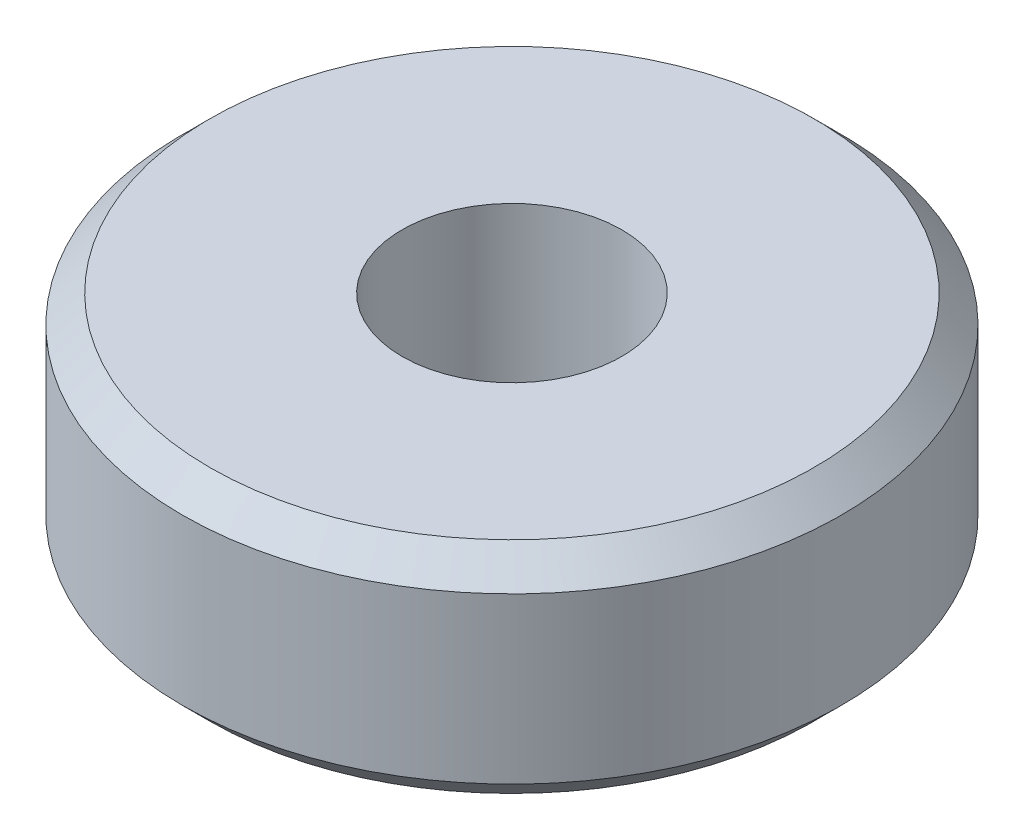
from build123d import *

# Parameters (mm, degrees)
SKETCH1_R           = 6
SKETCH1_R_2         = 2
BOSS_EXTRUDE1_DEPTH = 4
CHAMFER1_SIZE       = 0.5


with BuildPart() as part:
    # Sketch1 → Boss-Extrude1 (new body)
    with BuildSketch(Plane(origin=(0, 0, 0), x_dir=(1, 0, 0), z_dir=(0, 1, 0))):
        Circle(SKETCH1_R)
        Circle(SKETCH1_R_2, mode=Mode.SUBTRACT)
    extrude(amount=BOSS_EXTRUDE1_DEPTH)

    # Chamfer1
    chamfer1_edges = [part.edges().sort_by_distance(p)[0] for p in [
        (-6, 0, 0),
        (-6, 4, 0),
    ]]
    chamfer(chamfer1_edges, length=CHAMFER1_SIZE)


solid = part.part
